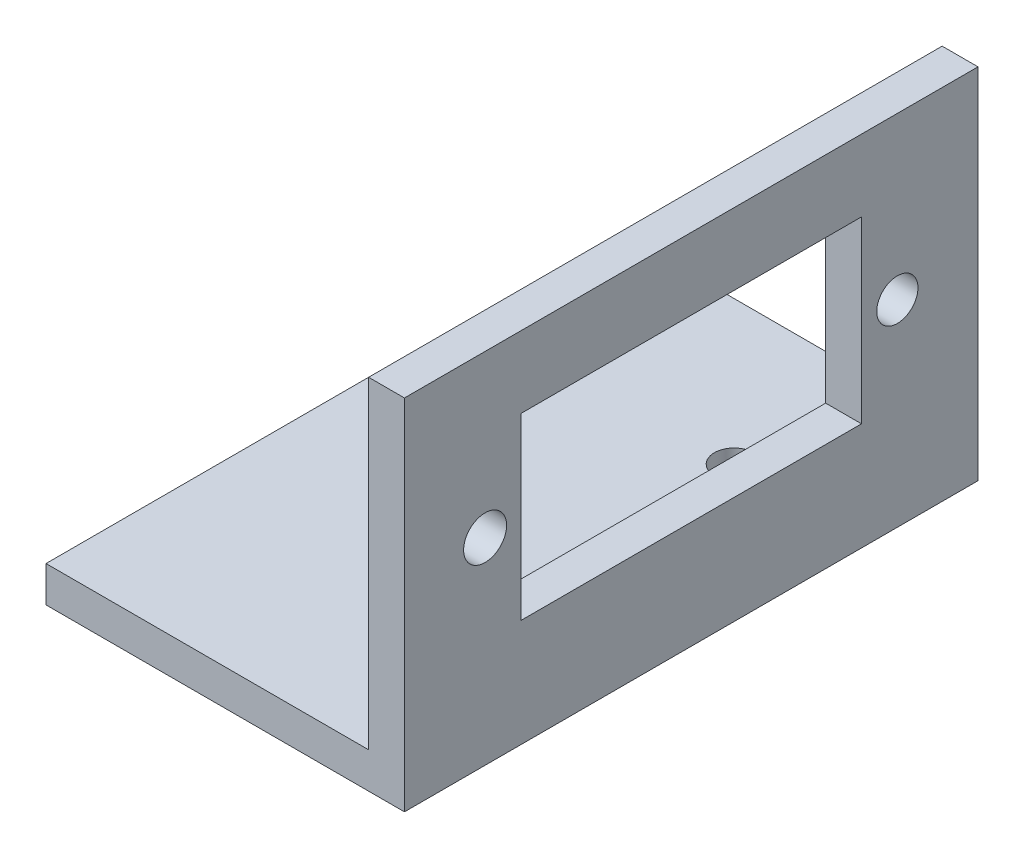
from build123d import *

# Parameters (mm, degrees)
EXTRUDE_1_DEPTH     = 16
SKETCH_4_R          = 1.15
SKETCH_4_R_2        = 1.2
SKETCH_4_W          = 19
SKETCH_4_H          = 10
CUT_EXTRUDE_1_DEPTH = 30
SKETCH_5_R          = 1.1
CUT_EXTRUDE_2_DEPTH = 30


with BuildPart() as part:
    # 草图2 → 凸台-拉伸1 (new body, symmetric)
    with BuildSketch(Plane.XY):
        Polygon((-20, 0), (0, 0), (0, 20), (-2, 20), (-2, 2), (-20, 2), align=None)
    extrude(amount=EXTRUDE_1_DEPTH, both=True)

    # 草图4 → 切除-拉伸1 (cut)
    with BuildSketch(Plane(origin=(0, 0, 0), x_dir=(0, 0, -1), z_dir=(1, 0, 0))):
        with Locations((11.5, 11)):
            Circle(SKETCH_4_R)
        with Locations((-11.5, 11)):
            Circle(SKETCH_4_R_2)
        with Locations((0, 11)):
            Rectangle(SKETCH_4_W, SKETCH_4_H)
    extrude(amount=-CUT_EXTRUDE_1_DEPTH, mode=Mode.SUBTRACT)

    # 草图5 → 切除-拉伸2 (cut)
    with BuildSketch(Plane(origin=(0, 2, 0), x_dir=(1, 0, 0), z_dir=(0, 1, 0))):
        with Locations((-5.609756098, 8)):
            Circle(SKETCH_5_R)
        with Locations((-5.609756098, -8)):
            Circle(SKETCH_5_R)
    extrude(amount=-CUT_EXTRUDE_2_DEPTH, mode=Mode.SUBTRACT)


solid = part.part
